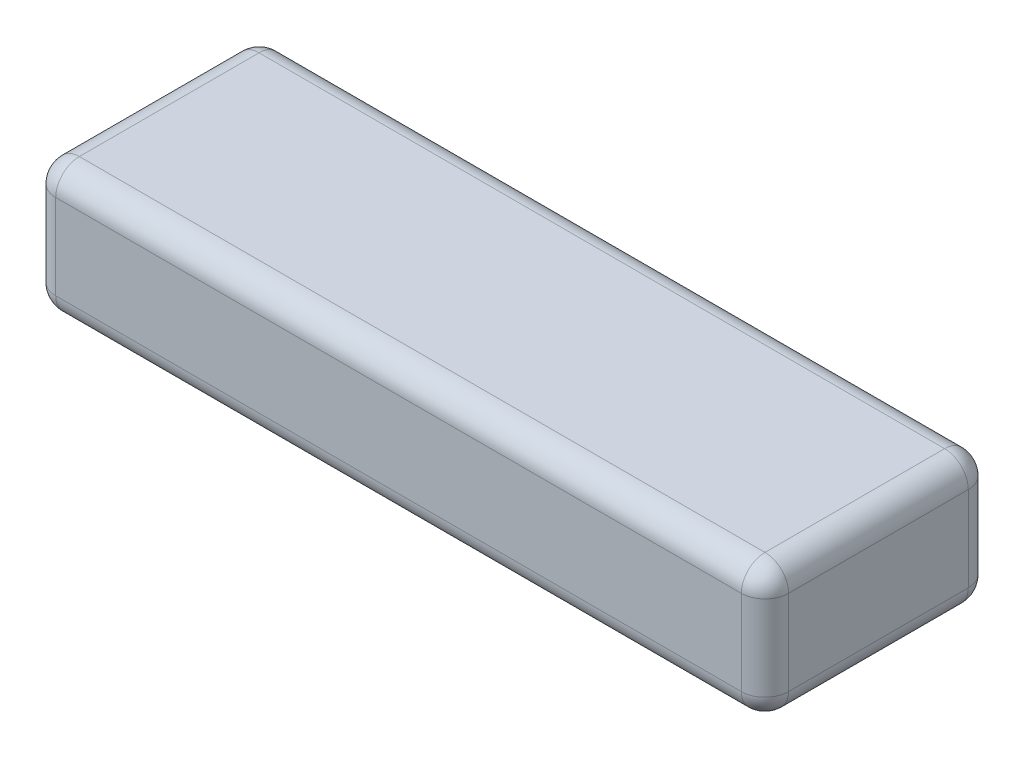
from build123d import *

# Parameters (mm, degrees)
SKIZZE1_W                       = 155
SKIZZE1_H                       = 48
AUFSATZ_LINEAR_AUSTRAGEN1_DEPTH = 28
VERRUNDUNG1_R                   = 5


with BuildPart() as part:
    # Skizze1 → Aufsatz-Linear austragen1 (new body)
    with BuildSketch(Plane(origin=(0, 0, 0), x_dir=(1, 0, 0), z_dir=(0, 1, 0))):
        with Locations((77.5, 24)):
            Rectangle(SKIZZE1_W, SKIZZE1_H)
    extrude(amount=AUFSATZ_LINEAR_AUSTRAGEN1_DEPTH)

    # Verrundung1
    verrundung1_edges = [part.edges().sort_by_distance(p)[0] for p in [
        (155, 28, -24),
        (77.5, 28, -48),
        (0, 28, -24),
        (77.5, 0, -48),
        (155, 0, -24),
        (77.5, 0, 0),
        (0, 0, -24),
        (0, 14, -48),
        (155, 14, -48),
        (155, 14, 0),
        (0, 14, 0),
        (77.5, 28, 0),
    ]]
    fillet(verrundung1_edges, radius=VERRUNDUNG1_R)


solid = part.part
